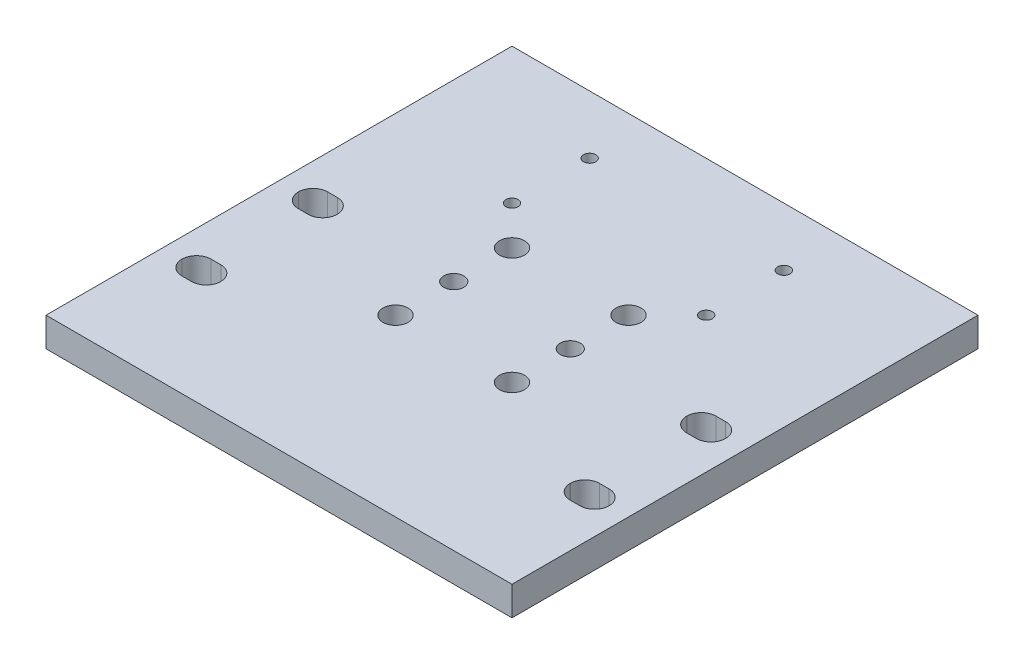
from build123d import *

# Parameters (mm, degrees)
SKETCH1_W                    = 152.4
SKETCH1_H                    = 152.4
EXTRUDE1_DEPTH               = 9.525
CUT_EXTRUDE1_DEPTH           = 10.525
F_10_32_TAPPED_HOLE1_D       = 4.0386
F_10_32_TAPPED_HOLE1_DEPTH   = 13.6144
F_10_32_TAPPED_HOLE1_TIP     = 1.213317848
SKETCH5_R                    = 4.09575
CUT_EXTRUDE2_DEPTH           = 10.525
F_5_16_18_TAPPED_HOLE1_D     = 6.5278
F_5_16_18_TAPPED_HOLE1_DEPTH = 22.9362
F_5_16_18_TAPPED_HOLE1_TIP   = 1.961148974


with BuildPart() as part:
    # Sketch1 → Extrude1 (new body)
    with BuildSketch(Plane(origin=(0, 0, 0), x_dir=(1, 0, 0), z_dir=(0, 1, 0))):
        with Locations((76.2, 76.2)):
            Rectangle(SKETCH1_W, SKETCH1_H)
    extrude(amount=EXTRUDE1_DEPTH)

    # Sketch2 → Cut-Extrude1 (cut, through all)
    with BuildSketch(Plane(origin=(0, 9.525, 0), x_dir=(1, 0, 0), z_dir=(0, 1, 0))):
        with BuildLine():
            Line((141.2875, 33.3248), (138.1125, 33.3248))
            ThreePointArc((138.1125, 33.3248), (134.744903955, 34.719703955), (133.35, 38.0873))
            Line((133.35, 38.0873), (133.35, 38.1127))
            ThreePointArc((133.35, 38.1127), (134.744903955, 41.480296045), (138.1125, 42.8752))
            Line((138.1125, 42.8752), (141.2875, 42.8752))
            ThreePointArc((141.2875, 42.8752), (144.655096045, 41.480296045), (146.05, 38.1127))
            Line((146.05, 38.1127), (146.05, 38.0873))
            ThreePointArc((146.05, 38.0873), (144.655096045, 34.719703955), (141.2875, 33.3248))
        make_face()
        with BuildLine():
            Line((19.05, 38.0873), (19.05, 38.1127))
            ThreePointArc((19.05, 38.1127), (17.655096045, 41.480296045), (14.2875, 42.8752))
            Line((14.2875, 42.8752), (11.1125, 42.8752))
            ThreePointArc((11.1125, 42.8752), (7.744903955, 41.480296045), (6.35, 38.1127))
            Line((6.35, 38.1127), (6.35, 38.0873))
            ThreePointArc((6.35, 38.0873), (7.744903955, 34.719703955), (11.1125, 33.3248))
            Line((11.1125, 33.3248), (14.2875, 33.3248))
            ThreePointArc((14.2875, 33.3248), (17.655096045, 34.719703955), (19.05, 38.0873))
        make_face()
        with BuildLine():
            Line((11.1125, 80.9752), (14.2875, 80.9752))
            ThreePointArc((14.2875, 80.9752), (17.655096045, 79.580296045), (19.05, 76.2127))
            Line((19.05, 76.2127), (19.05, 76.1873))
            ThreePointArc((19.05, 76.1873), (17.655096045, 72.819703955), (14.2875, 71.4248))
            Line((14.2875, 71.4248), (11.1125, 71.4248))
            ThreePointArc((11.1125, 71.4248), (7.744903955, 72.819703955), (6.35, 76.1873))
            Line((6.35, 76.1873), (6.35, 76.2127))
            ThreePointArc((6.35, 76.2127), (7.744903955, 79.580296045), (11.1125, 80.9752))
        make_face()
        with BuildLine():
            Line((133.35, 76.2127), (133.35, 76.1873))
            ThreePointArc((133.35, 76.1873), (134.744903955, 72.819703955), (138.1125, 71.4248))
            Line((138.1125, 71.4248), (141.2875, 71.4248))
            ThreePointArc((141.2875, 71.4248), (144.655096045, 72.819703955), (146.05, 76.1873))
            Line((146.05, 76.1873), (146.05, 76.2127))
            ThreePointArc((146.05, 76.2127), (144.655096045, 79.580296045), (141.2875, 80.9752))
            Line((141.2875, 80.9752), (138.1125, 80.9752))
            ThreePointArc((138.1125, 80.9752), (134.744903955, 79.580296045), (133.35, 76.2127))
        make_face()
    extrude(amount=-CUT_EXTRUDE1_DEPTH, mode=Mode.SUBTRACT)

    # #10-32 Tapped Hole1
    with Locations(Plane(origin=(0, 9.525, 0), x_dir=(-1, 0, 0), z_dir=(0, 1, 0))):
        with Locations((-44.45, -107.95), (-107.95, -107.95), (-107.95, -133.35), (-44.45, -133.35)):
            Hole(F_10_32_TAPPED_HOLE1_D / 2, depth=F_10_32_TAPPED_HOLE1_DEPTH)
            with Locations((0, 0, -(F_10_32_TAPPED_HOLE1_DEPTH + F_10_32_TAPPED_HOLE1_TIP / 2))):  # 118° drill point
                Cone(0, F_10_32_TAPPED_HOLE1_D / 2, F_10_32_TAPPED_HOLE1_TIP, mode=Mode.SUBTRACT)

    # Sketch5 → Cut-Extrude2 (cut, through all)
    with BuildSketch(Plane(origin=(0, 9.525, 0), x_dir=(1, 0, 0), z_dir=(0, 1, 0))):
        with Locations(Location((57.15, 95.25, 0), (0, 0, 270))):  # turned: the seam where the file's is
            Circle(SKETCH5_R)
        with Locations(Location((95.25, 95.25, 0), (0, 0, 90))):  # turned: the seam where the file's is
            Circle(SKETCH5_R)
        with Locations(Location((57.15, 57.15, 0), (0, 0, 90))):  # turned: the seam where the file's is
            Circle(SKETCH5_R)
        with Locations(Location((95.25, 57.15, 0), (0, 0, 270))):  # turned: the seam where the file's is
            Circle(SKETCH5_R)
    extrude(amount=-CUT_EXTRUDE2_DEPTH, mode=Mode.SUBTRACT)

    # 5/16-18 Tapped Hole1
    with Locations(Plane(origin=(0, 9.525, 0), x_dir=(-1, 0, 0), z_dir=(0, 1, 0))):
        with Locations((-57.15, -76.2), (-95.25, -76.2)):
            Hole(F_5_16_18_TAPPED_HOLE1_D / 2, depth=F_5_16_18_TAPPED_HOLE1_DEPTH)
            with Locations((0, 0, -(F_5_16_18_TAPPED_HOLE1_DEPTH + F_5_16_18_TAPPED_HOLE1_TIP / 2))):  # 118° drill point
                Cone(0, F_5_16_18_TAPPED_HOLE1_D / 2, F_5_16_18_TAPPED_HOLE1_TIP, mode=Mode.SUBTRACT)


solid = part.part
